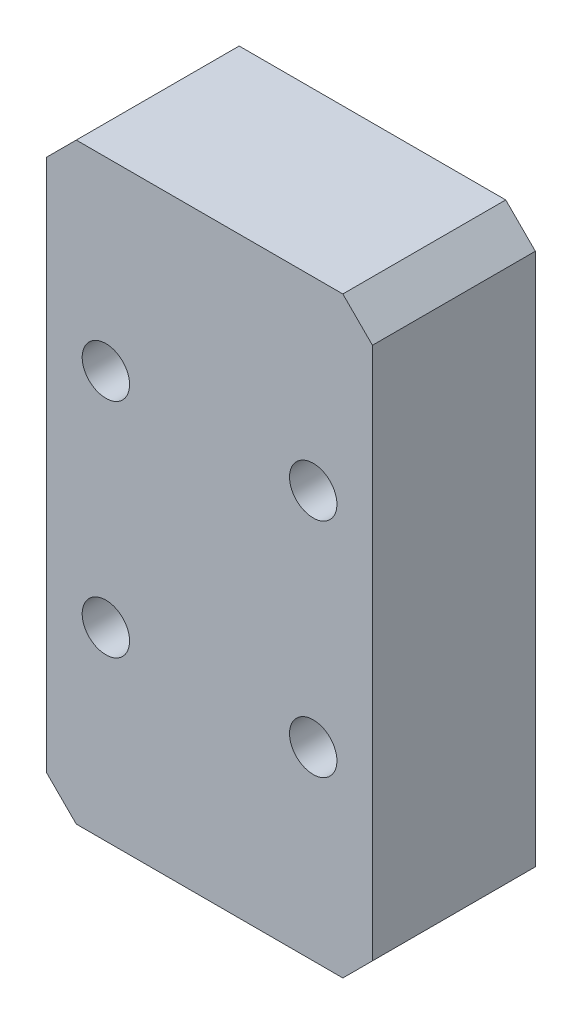
from build123d import *

# Parameters (mm, degrees)
SKETCH_1_W                  = 22
SKETCH_1_H                  = 40
EXTRUDE_1_DEPTH             = 11
SKETCH_4_R                  = 1.6
CUT_EXTRUDE_3_DEPTH         = 12
PATTERN_LINEAR_1_COUNT      = 2
PATTERN_LINEAR_1_PITCH      = 14
PATTERN_LINEAR_1_COUNT_DIR2 = 2
PATTERN_LINEAR_1_PITCH_DIR2 = 15
CHAMFER_1_SIZE              = 2


with BuildPart() as part:
    # 草圖1 → 填料-伸長1 (new body)
    with BuildSketch(Plane.XY):
        Rectangle(SKETCH_1_W, SKETCH_1_H)
    extrude(amount=EXTRUDE_1_DEPTH)

    # 草圖4 → 除料-伸長3 (cut, through all)
    with BuildSketch(Plane.XY.offset(11)):
        with Locations((-7, 7.5)):
            Circle(SKETCH_4_R)
    cut_extrude_3 = extrude(amount=-CUT_EXTRUDE_3_DEPTH, mode=Mode.SUBTRACT)

    # 直線複製排列1: Cut-Extrude 3 2 × 2
    with Locations(*[(i * PATTERN_LINEAR_1_PITCH, -j * PATTERN_LINEAR_1_PITCH_DIR2, 0) for i in range(PATTERN_LINEAR_1_COUNT) for j in range(PATTERN_LINEAR_1_COUNT_DIR2) if (i, j) != (0, 0)]):
        add(cut_extrude_3, mode=Mode.SUBTRACT)

    # 導角1
    chamfer_1_edges = [part.edges().sort_by_distance(p)[0] for p in [
        (11, -20, 5.5),
        (-11, -20, 5.5),
        (-11, 20, 5.5),
        (11, 20, 5.5),
    ]]
    chamfer(chamfer_1_edges, length=CHAMFER_1_SIZE)


solid = part.part
